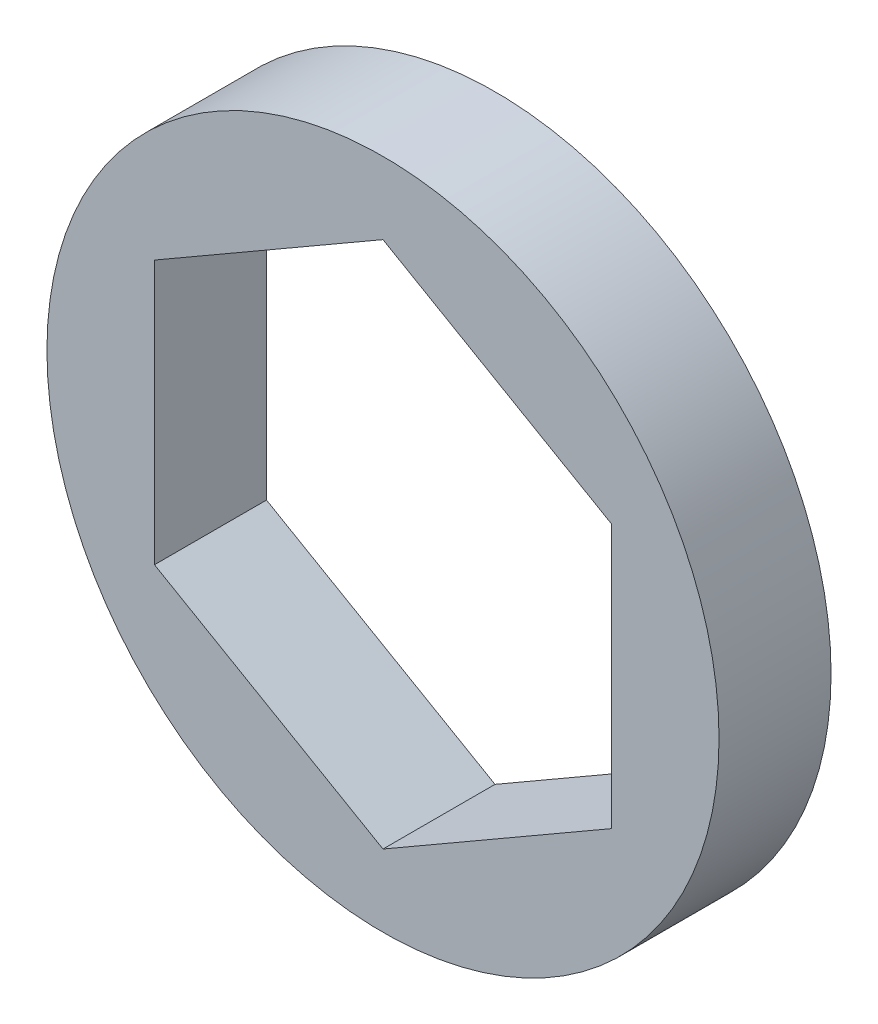
from build123d import *

# Parameters (mm, degrees)
SKETCH1_R           = 9.525
BOSS_EXTRUDE1_DEPTH = 3.175


with BuildPart() as part:
    # Sketch1 → Boss-Extrude1 (new body)
    with BuildSketch(Plane(origin=(0, 0, -1.5875), x_dir=(-1, 0, 0), z_dir=(0, 0, -1))):
        Circle(SKETCH1_R)
        Polygon((6.477, 3.739497694), (6.477, -3.739497694), (0, -7.478995387), (-6.477, -3.739497694), (-6.477, 3.739497694), (0, 7.478995387), align=None, mode=Mode.SUBTRACT)
    extrude(amount=-BOSS_EXTRUDE1_DEPTH)


solid = part.part
